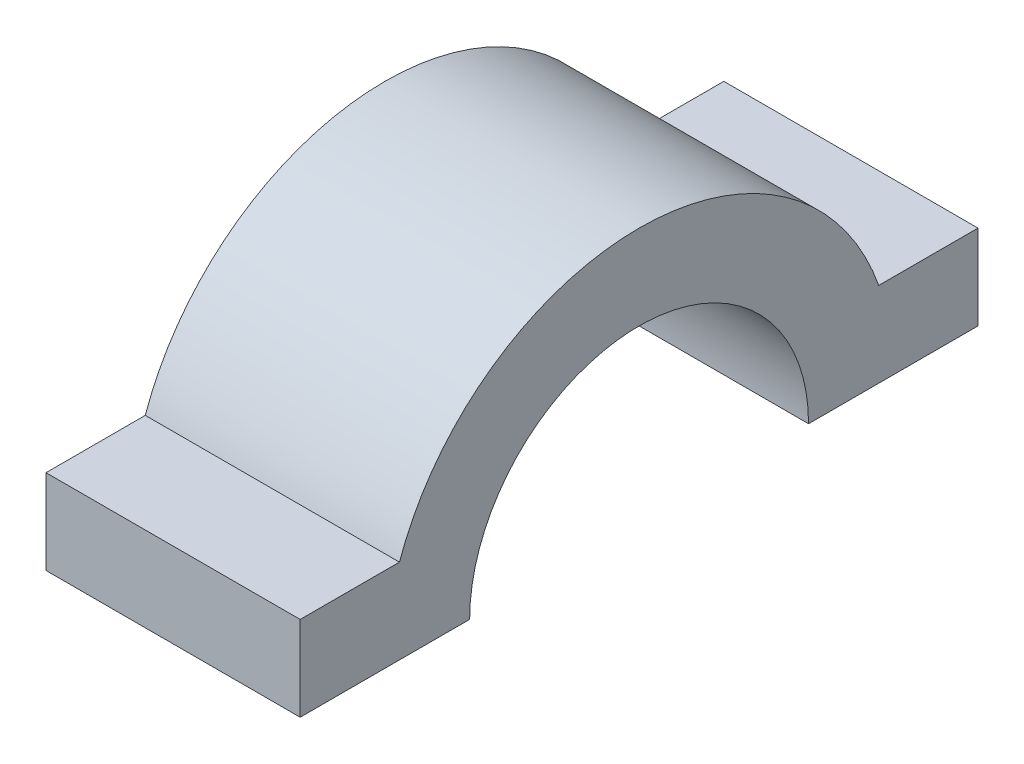
from build123d import *

# Parameters (mm, degrees)
SALIENTE_EXTRUIR1_DEPTH = 15


with BuildPart() as part:
    # Croquis1 → Saliente-Extruir1 (new body)
    with BuildSketch(Plane(origin=(0, 0, 0), x_dir=(0, 0, -1), z_dir=(1, 0, 0))):
        with BuildLine():
            Line((-10, 0), (-20, 0))
            Line((-20, 0), (-20, 5))
            Line((-20, 5), (-14.142135624, 5))
            ThreePointArc((-14.142135624, 5), (0, 15), (14.142135624, 5))
            Line((14.142135624, 5), (20, 5))
            Line((20, 5), (20, 0))
            Line((20, 0), (10, 0))
            ThreePointArc((10, 0), (0, 10), (-10, 0))
        make_face()
    extrude(amount=SALIENTE_EXTRUIR1_DEPTH)


solid = part.part
